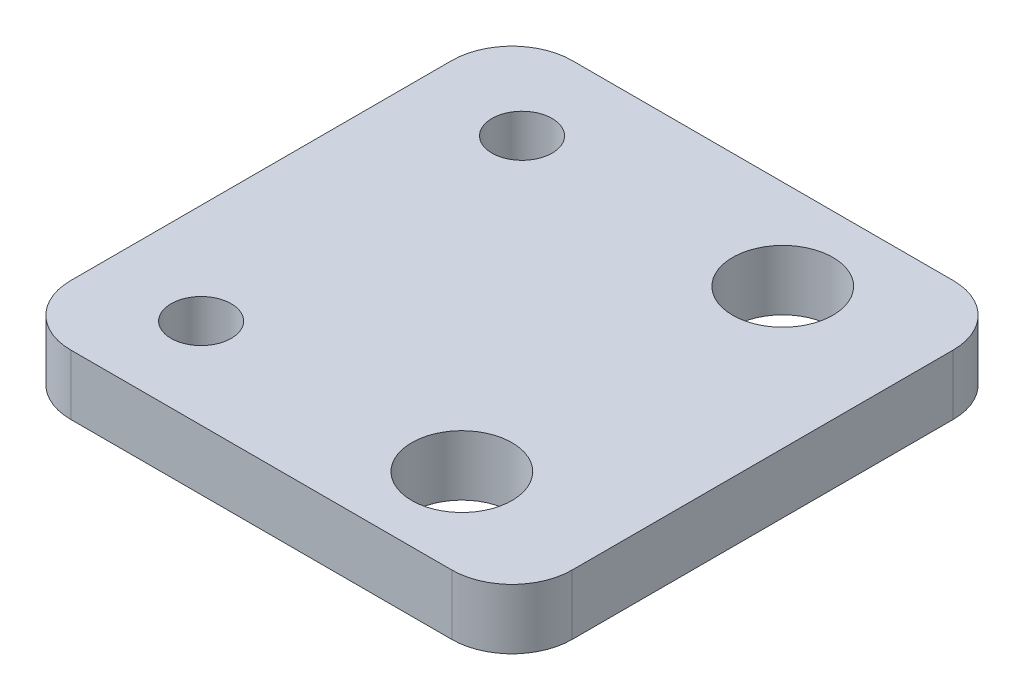
from build123d import *

# Parameters (mm, degrees)
SKETCH3_R           = 2.5
SKETCH3_R_2         = 1.5
BOSS_EXTRUDE1_DEPTH = 3


with BuildPart() as part:
    # Sketch3 → Boss-Extrude1 (new body)
    with BuildSketch(Plane(origin=(0, 0, 0), x_dir=(1, 0, 0), z_dir=(0, 1, 0))):
        with BuildLine():
            Line((-9.5, 12.5), (9.5, 12.5))
            ThreePointArc((9.5, 12.5), (11.621320344, 11.621320344), (12.5, 9.5))
            Line((12.5, 9.5), (12.5, -9.5))
            ThreePointArc((12.5, -9.5), (11.621320344, -11.621320344), (9.5, -12.5))
            Line((9.5, -12.5), (-9.5, -12.5))
            ThreePointArc((-9.5, -12.5), (-11.621320344, -11.621320344), (-12.5, -9.5))
            Line((-12.5, -9.5), (-12.5, 9.5))
            ThreePointArc((-12.5, 9.5), (-11.621320344, 11.621320344), (-9.5, 12.5))
        make_face()
        with Locations((5.5, 8)):
            Circle(SKETCH3_R, mode=Mode.SUBTRACT)
        with Locations((5.5, -8)):
            Circle(SKETCH3_R, mode=Mode.SUBTRACT)
        with Locations((-7.5, 8)):
            Circle(SKETCH3_R_2, mode=Mode.SUBTRACT)
        with Locations((-7.5, -8)):
            Circle(SKETCH3_R_2, mode=Mode.SUBTRACT)
    extrude(amount=BOSS_EXTRUDE1_DEPTH)


solid = part.part
